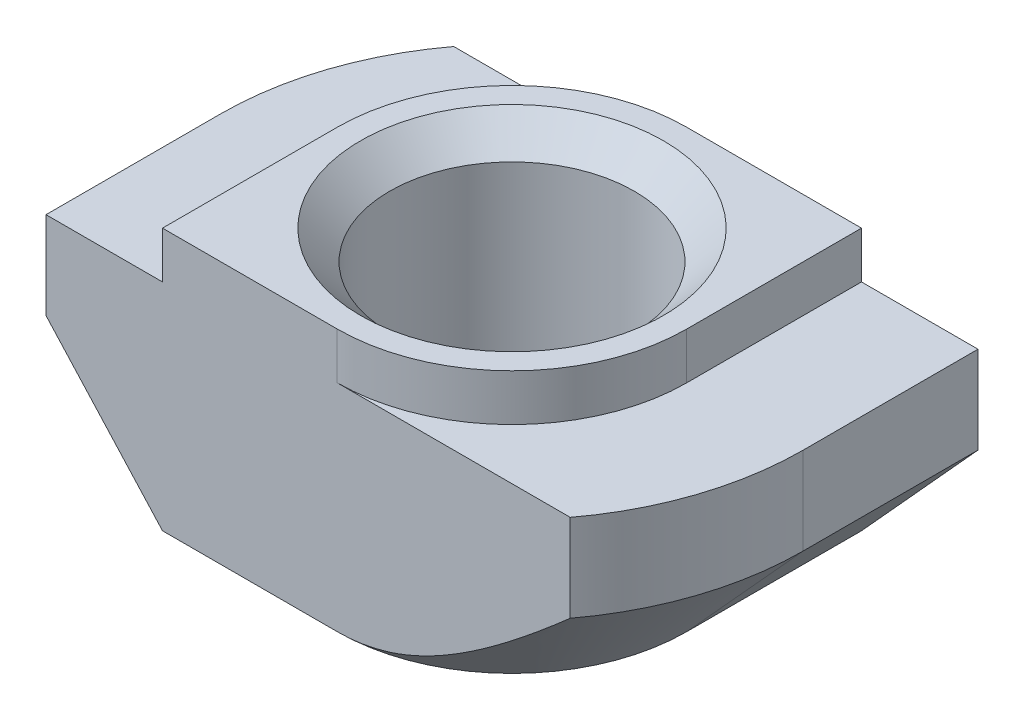
from build123d import *

# Parameters (mm, degrees)
EXTRUDE_1_DEPTH     = 3
CUT_EXTRUDE_1_DEPTH = 0.8
CUT_EXTRUDE_2_DEPTH = 4.7


with BuildPart() as part:
    # Эскиз1 → Бобышка-Вытянуть1 (new body, symmetric)
    with BuildSketch(Plane.XY):
        Polygon((3, 0), (-3, 0), (-3, -0.8), (-5, -0.8), (-5, -4.5), (5, -4.5), (5, -0.8), (3, -0.8), align=None)
    extrude(amount=EXTRUDE_1_DEPTH, both=True)

    # Эскиз3 → Отверстие обработанное метчиком M51 (revolve, cut)
    with BuildSketch(Plane(origin=(0, 0, 0), x_dir=(0, 0, 1), z_dir=(1, 0, 0))):
        Polygon((0, 0), (0, 4.5), (2.6, 4.5), (2.1, 4), (2.1, 0.5), (2.6, 0), align=None)
    revolve(axis=Axis((0, 6.35, 0), (0, -1, 0)), mode=Mode.SUBTRACT)

    # Эскиз4 → Вырез-Вытянуть1 (cut)
    with BuildSketch(Plane(origin=(0, 0, 0), x_dir=(1, 0, 0), z_dir=(0, 1, 0))):
        with BuildLine():
            Line((-3, 3), (-3, 0))
            ThreePointArc((-3, 0), (-2.121320344, 2.121320344), (0, 3))
            Line((0, 3), (-3, 3))
        make_face()
        with BuildLine():
            Line((0, -3), (3, -3))
            Line((3, -3), (3, 0))
            ThreePointArc((3, 0), (2.121320344, -2.121320344), (0, -3))
        make_face()
    extrude(amount=-CUT_EXTRUDE_1_DEPTH, mode=Mode.SUBTRACT)

    # Эскиз5 → Вырез-Вытянуть2 (cut, through all)
    with BuildSketch(Plane(origin=(0, -0.8, 0), x_dir=(1, 0, 0), z_dir=(0, 1, 0))):
        with BuildLine():
            Line((-5, 0), (-5, 3))
            Line((-5, 3), (-4, 3))
            ThreePointArc((-4, 3), (-4.74341649, 1.58113883), (-5, 0))
        make_face()
        with BuildLine():
            Line((5, 0), (5, -3))
            Line((5, -3), (4, -3))
            ThreePointArc((4, -3), (4.74341649, -1.58113883), (5, 0))
        make_face()
    extrude(amount=-CUT_EXTRUDE_2_DEPTH, mode=Mode.SUBTRACT)

    # Вырез-По траектории1: sweep along a path in Эскиз7
    with BuildLine(Plane.XZ.offset(4.5)) as sweep_1_path:
        Line((0, 5), (-5, 5))
        Line((-5, 5), (-5, 0))
        ThreePointArc((-5, 0), (-3.535533906, -3.535533906), (0, -5))
        Line((0, -5), (5, -5))
        Line((5, -5), (5, 0))
        ThreePointArc((5, 0), (3.535533906, 3.535533906), (0, 5))
    # Эскиз6 → Вырез-По траектории1 (sweep, cut)
    with BuildSketch(Plane.XY.offset(3)):
        Polygon((-5, -2.3), (-5, -4.5), (-3, -4.5), align=None)
    sweep(path=sweep_1_path.line, transition=Transition.RIGHT, mode=Mode.SUBTRACT)


solid = part.part
